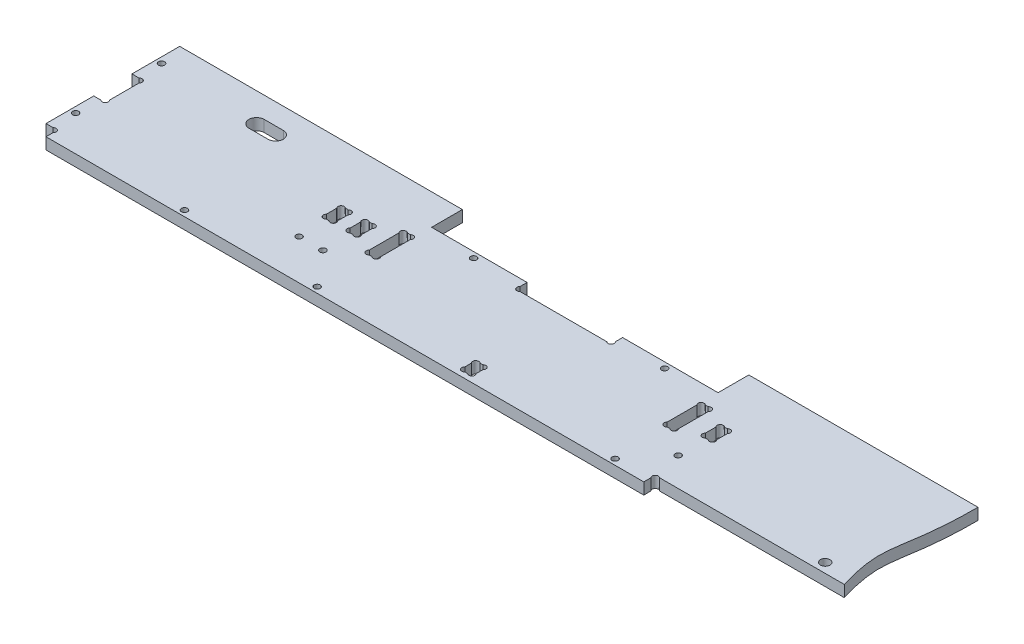
from build123d import *

# Parameters (mm, degrees)
ESQUISSE1_R        = 1.6
ESQUISSE1_R_2      = 2.5
BOSS_EXTRU_1_DEPTH = 6


with BuildPart() as part:
    # Esquisse1 → Boss.-Extru.1 (new body)
    with BuildSketch(Plane(origin=(0, 0, 0), x_dir=(1, 0, 0), z_dir=(0, 1, 0))):
        with BuildLine():
            Line((6, 33.2627417), (6, 48.7372583))
            ThreePointArc((6, 48.7372583), (6, 51), (3.7372583, 51))
            Line((3.7372583, 51), (0, 51))
            Line((0, 51), (0, 76))
            Line((0, 76), (148, 76))
            Line((148, 76), (148, 59.9))
            Line((148, 59.9), (198, 59.9))
            Line((198, 59.9), (198, 56.1627417))
            ThreePointArc((198, 56.1627417), (198, 53.9), (200.2627417, 53.9))
            Line((200.2627417, 53.9), (245.7372583, 53.9))
            ThreePointArc((245.7372583, 53.9), (248, 53.9), (248, 56.1627417))
            Line((248, 56.1627417), (248, 59.9))
            Line((248, 59.9), (298, 59.9))
            Line((298, 59.9), (298, 76))
            Line((298, 76), (418, 76))
            add(Edge.make_bspline(
                [(418, 76), (417.983253291, 33.794946315), (408.880818962, 36.469928489), (418, 6)],
                knots=[0, 0, 0, 0, 1, 1, 1, 1], degree=3))
            Line((418, 6), (321.2627417, 6))
            ThreePointArc((321.2627417, 6), (319, 6), (319, 3.7372583))
            Line((319, 3.7372583), (319, 0))
            Line((319, 0), (6, 0))
            Line((6, 0), (6, 3.7372583))
            ThreePointArc((6, 3.7372583), (6, 6), (3.7372583, 6))
            Line((3.7372583, 6), (0, 6))
            Line((0, 6), (0, 31))
            Line((0, 31), (3.7372583, 31))
            ThreePointArc((3.7372583, 31), (6, 31), (6, 33.2627417))
        make_face()
        with Locations(Location((75.5, 3, 0), (0, 0, 270))):  # turned: the seam where the file's is
            Circle(ESQUISSE1_R, mode=Mode.SUBTRACT)
        with Locations(Location((3, 63.5, 0), (0, 0, 270))):  # turned: the seam where the file's is
            Circle(ESQUISSE1_R, mode=Mode.SUBTRACT)
        with Locations(Location((3, 18.5, 0), (0, 0, 90))):  # turned: the seam where the file's is
            Circle(ESQUISSE1_R, mode=Mode.SUBTRACT)
        with Locations(Location((130, 21, 0), (0, 0, 270))):  # turned: the seam where the file's is
            Circle(ESQUISSE1_R, mode=Mode.SUBTRACT)
        with Locations(Location((145, 3, 0), (0, 0, 270))):  # turned: the seam where the file's is
            Circle(ESQUISSE1_R, mode=Mode.SUBTRACT)
        with Locations(Location((301, 3, 0), (0, 0, 90))):  # turned: the seam where the file's is
            Circle(ESQUISSE1_R, mode=Mode.SUBTRACT)
        with Locations(Location((316, 21, 0), (0, 0, 90))):  # turned: the seam where the file's is
            Circle(ESQUISSE1_R, mode=Mode.SUBTRACT)
        with Locations(Location((117.5, 21, 0), (0, 0, 90))):  # turned: the seam where the file's is
            Circle(ESQUISSE1_R, mode=Mode.SUBTRACT)
        with Locations(Location((273, 56.9, 0), (0, 0, 270))):  # turned: the seam where the file's is
            Circle(ESQUISSE1_R, mode=Mode.SUBTRACT)
        with Locations(Location((173, 56.9, 0), (0, 0, 90))):  # turned: the seam where the file's is
            Circle(ESQUISSE1_R, mode=Mode.SUBTRACT)
        with Locations(Location((403, 11, 0), (0, 0, 270))):  # turned: the seam where the file's is
            Circle(ESQUISSE1_R_2, mode=Mode.SUBTRACT)
        with BuildLine():
            Line((300.2627417, 51), (301.7372583, 51))
            ThreePointArc((301.7372583, 51), (304, 51), (304, 48.7372583))
            Line((304, 48.7372583), (304, 33.2627417))
            ThreePointArc((304, 33.2627417), (304, 31), (301.7372583, 31))
            Line((301.7372583, 31), (300.2627417, 31))
            ThreePointArc((300.2627417, 31), (298, 31), (298, 33.2627417))
            Line((298, 33.2627417), (298, 48.7372583))
            ThreePointArc((298, 48.7372583), (298, 51), (300.2627417, 51))
        make_face(mode=Mode.SUBTRACT)
        with BuildLine():
            Line((130.7372583, 46), (129.2627417, 46))
            ThreePointArc((129.2627417, 46), (127, 46), (127, 43.7372583))
            Line((127, 43.7372583), (127, 38.2627417))
            ThreePointArc((127, 38.2627417), (127, 36), (129.2627417, 36))
            Line((129.2627417, 36), (130.7372583, 36))
            ThreePointArc((130.7372583, 36), (133, 36), (133, 38.2627417))
            Line((133, 38.2627417), (133, 43.7372583))
            ThreePointArc((133, 43.7372583), (133, 46), (130.7372583, 46))
        make_face(mode=Mode.SUBTRACT)
        with BuildLine():
            Line((313, 38.2627417), (313, 43.7372583))
            ThreePointArc((313, 43.7372583), (313, 46), (315.2627417, 46))
            Line((315.2627417, 46), (316.7372583, 46))
            ThreePointArc((316.7372583, 46), (319, 46), (319, 43.7372583))
            Line((319, 43.7372583), (319, 38.2627417))
            ThreePointArc((319, 38.2627417), (319, 36), (316.7372583, 36))
            Line((316.7372583, 36), (315.2627417, 36))
            ThreePointArc((315.2627417, 36), (313, 36), (313, 38.2627417))
        make_face(mode=Mode.SUBTRACT)
        with BuildLine():
            Line((148, 33.2627417), (148, 48.7372583))
            ThreePointArc((148, 48.7372583), (148, 51), (145.7372583, 51))
            Line((145.7372583, 51), (144.2627417, 51))
            ThreePointArc((144.2627417, 51), (142, 51), (142, 48.7372583))
            Line((142, 48.7372583), (142, 33.2627417))
            ThreePointArc((142, 33.2627417), (142, 31), (144.2627417, 31))
            Line((144.2627417, 31), (145.7372583, 31))
            ThreePointArc((145.7372583, 31), (148, 31), (148, 33.2627417))
        make_face(mode=Mode.SUBTRACT)
        with BuildLine():
            Line((114.5, 38.2627417), (114.5, 43.7372583))
            ThreePointArc((114.5, 43.7372583), (114.5, 46), (116.7627417, 46))
            Line((116.7627417, 46), (118.2372583, 46))
            ThreePointArc((118.2372583, 46), (120.5, 46), (120.5, 43.7372583))
            Line((120.5, 43.7372583), (120.5, 38.2627417))
            ThreePointArc((120.5, 38.2627417), (120.5, 36), (118.2372583, 36))
            Line((118.2372583, 36), (116.7627417, 36))
            ThreePointArc((116.7627417, 36), (114.5, 36), (114.5, 38.2627417))
        make_face(mode=Mode.SUBTRACT)
        with BuildLine():
            Line((55.25, 65), (65.25, 65))
            ThreePointArc((65.25, 65), (69.25, 61), (65.25, 57))
            Line((65.25, 57), (55.25, 57))
            ThreePointArc((55.25, 57), (51.25, 61), (55.25, 65))
        make_face(mode=Mode.SUBTRACT)
        with BuildLine():
            Line((220, 8.7372583), (220, 5.2627417))
            ThreePointArc((220, 5.2627417), (220, 3), (222.2627417, 3))
            Line((222.2627417, 3), (223.7372583, 3))
            ThreePointArc((223.7372583, 3), (226, 3), (226, 5.2627417))
            Line((226, 5.2627417), (226, 8.7372583))
            ThreePointArc((226, 8.7372583), (226, 11), (223.7372583, 11))
            Line((223.7372583, 11), (222.2627417, 11))
            ThreePointArc((222.2627417, 11), (220, 11), (220, 8.7372583))
        make_face(mode=Mode.SUBTRACT)
    extrude(amount=BOSS_EXTRU_1_DEPTH)


solid = part.part
